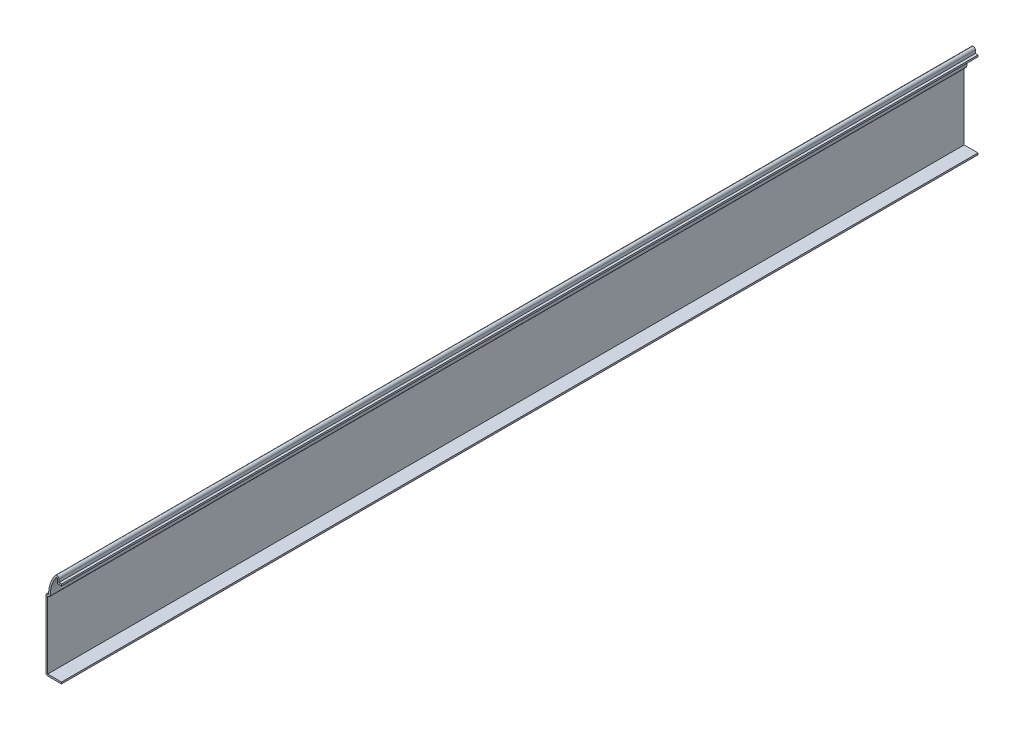
from build123d import *

# Parameters (mm, degrees)
EXTRUDE_THIN1_DEPTH = 563.5625
FILLET1_R           = 1.016


with BuildPart() as part:
    # Sketch1 → Extrude-Thin1 (new body)
    with BuildSketch(Plane.XY):
        with BuildLine():
            Line((0, 0), (-9.525, 0))
            Line((-9.525, 0), (-9.525, 43.65625))
            Line((-9.525, 43.65625), (-7.9375, 43.65625))
            ThreePointArc((-7.9375, 43.65625), (-6.894744616, 50.081998205), (-3.8735, 55.84825))
            ThreePointArc((-3.8735, 55.84825), (-2.455890737, 56.291077789), (-1.5875, 55.08625))
            Line((-1.5875, 55.08625), (-1.5875, 53.18125))
            Line((-1.5875, 53.18125), (0, 53.18125))
            Line((0, 53.18125), (0, 52.16525))
            Line((0, 52.16525), (-2.6035, 52.16525))
            Line((-2.6035, 52.16525), (-2.6035, 55.08625))
            ThreePointArc((-2.6035, 55.08625), (-2.777178147, 55.327215558), (-3.0607, 55.23865))
            ThreePointArc((-3.0607, 55.23865), (-6.085235087, 49.276497038), (-6.894744616, 42.64025))
            Line((-6.894744616, 42.64025), (-8.509, 42.64025))
            Line((-8.509, 42.64025), (-8.509, 1.016))
            Line((-8.509, 1.016), (0, 1.016))
            Line((0, 1.016), (0, 0))
        make_face()
    extrude(amount=-EXTRUDE_THIN1_DEPTH)

    # Fillet1
    fillet1_edges = [part.edges().sort_by_distance(p)[0] for p in [
        (-2.6035, 52.16525, -281.78125),
        (-6.894744616, 42.64025, -281.78125),
        (-9.525, 0, -281.78125),
        (-9.525, 43.65625, -281.78125),
    ]]
    fillet(fillet1_edges, radius=FILLET1_R)


solid = part.part
